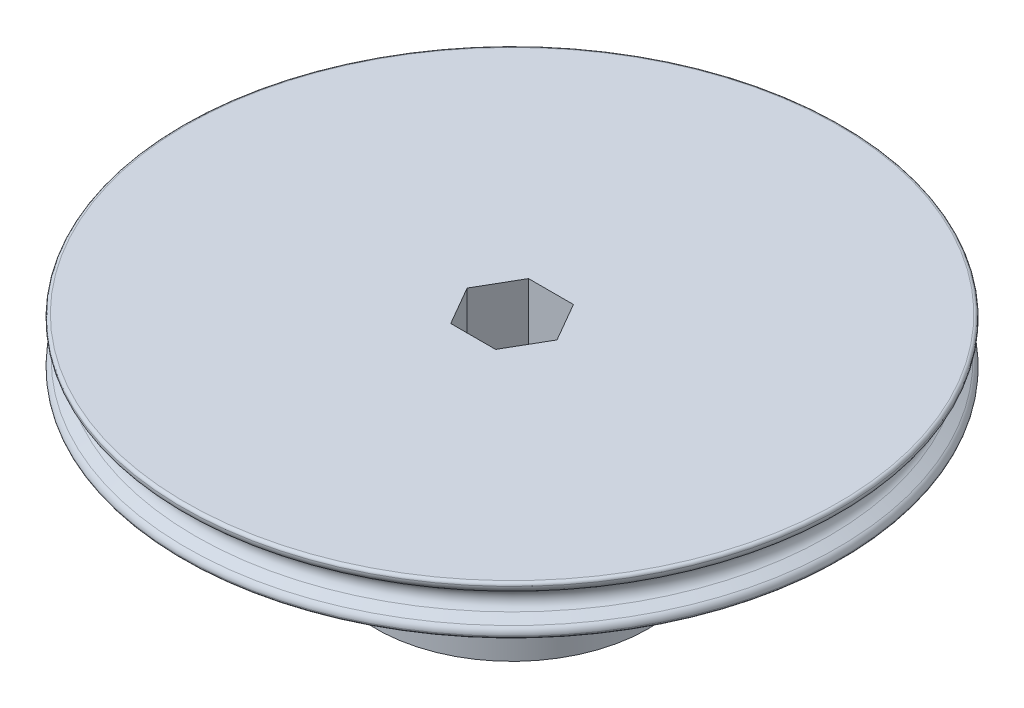
from build123d import *

# Parameters (mm, degrees)
CUT_EXTRUDE2_DEPTH  = 9.0000094
SKETCH3_R           = 22.225
BOSS_EXTRUDE1_DEPTH = 25.4


with BuildPart() as part:
    # Sketch1 → Revolve1 (revolve)
    with BuildSketch(Plane(origin=(0, 0, 0), x_dir=(0, 1, 0), z_dir=(0, 0, 1))):
        with BuildLine():
            Line((4.0000047, 0), (-4.0000047, 0))
            Line((-4.0000047, 0), (-4.0000047, 53.300621907))
            ThreePointArc((-4.0000047, 53.300621907), (-3.862299847, 53.645211447), (-3.525035946, 53.799994))
            ThreePointArc((-3.525035946, 53.799994), (-2.891173009, 53.65542644), (-2.425734949, 53.201499778))
            Line((-2.425734949, 53.201499778), (-1.558842609, 51.6999982))
            ThreePointArc((-1.558842609, 51.6999982), (0, 50.8), (1.558842609, 51.6999982))
            Line((1.558842609, 51.6999982), (2.425734949, 53.201499778))
            ThreePointArc((2.425734949, 53.201499778), (2.891173009, 53.65542644), (3.525035946, 53.799994))
            ThreePointArc((3.525035946, 53.799994), (3.862299847, 53.645211447), (4.0000047, 53.300621907))
            Line((4.0000047, 53.300621907), (4.0000047, 0))
        make_face()
    revolve(axis=Axis((0, 4.0000047, 0), (0, -1, 0)))

    # Sketch2 → Cut-Extrude2 (cut, through all)
    with BuildSketch(Plane.XZ.offset(4.0000047)):
        Polygon((7.332348419, 0), (3.666174209, 6.35), (-3.666174209, 6.35), (-7.332348419, 0), (-3.666174209, -6.35), (3.666174209, -6.35), align=None)
    extrude(amount=-CUT_EXTRUDE2_DEPTH, mode=Mode.SUBTRACT)

    # Sketch3 → Boss-Extrude1 (add)
    with BuildSketch(Plane.XZ.offset(4.0000047)):
        Circle(SKETCH3_R)
        Polygon((-3.666174209, 6.35), (-7.332348419, 0), (-3.666174209, -6.35), (3.666174209, -6.35), (7.332348419, 0), (3.666174209, 6.35), align=None, mode=Mode.SUBTRACT)
    extrude(amount=BOSS_EXTRUDE1_DEPTH)


solid = part.part
